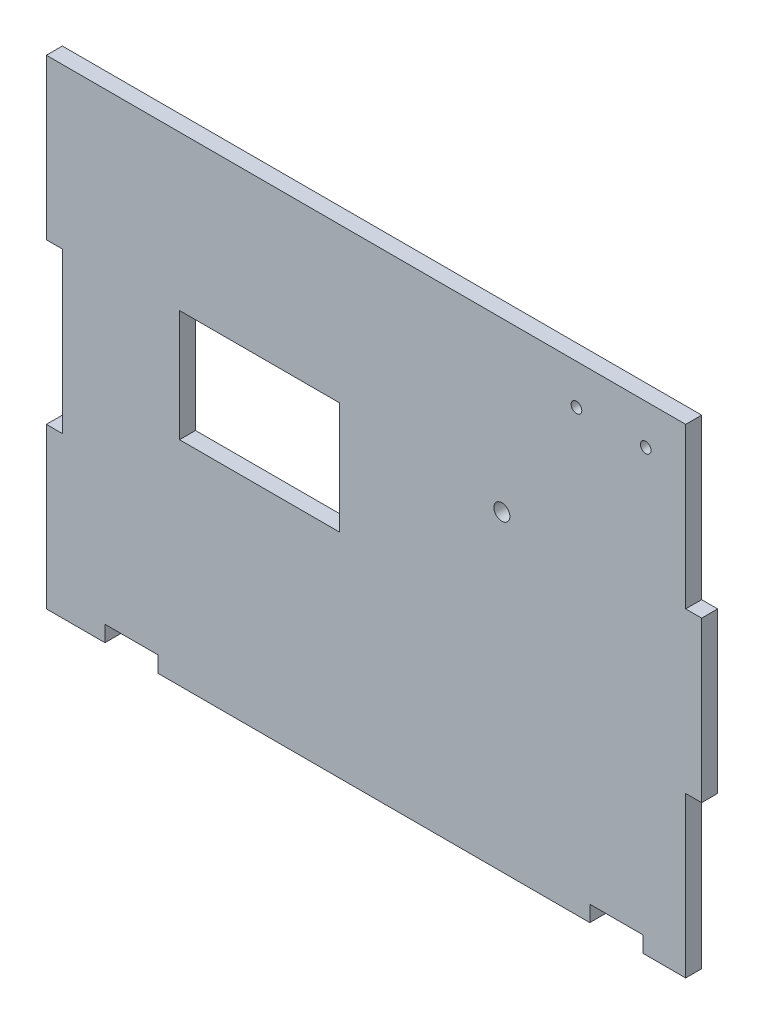
from build123d import *

# Parameters (mm, degrees)
MODEL_R             = 1
MODEL_R_2           = 1.5
MODEL_W             = 30
MODEL_H             = 21
BOSS_EXTRUDE1_DEPTH = 3


with BuildPart() as part:
    # Model → Boss-Extrude1 (new body)
    with BuildSketch(Plane.XY):
        Polygon((71.207281269, 100.913104874), (71.207281269, 70.913104874), (68.207281269, 70.913104874), (68.207281269, 40.913104874), (60.207281269, 40.913104874), (60.207281269, 43.913104874), (50.207281269, 43.913104874), (50.207281269, 40.913104874), (-30.792718731, 40.913104874), (-30.792718731, 43.913104874), (-40.792718731, 43.913104874), (-40.792718731, 40.913104874), (-51.792718731, 40.913104874), (-51.792718731, 70.913104874), (-48.792718731, 70.913104874), (-48.792718731, 100.913104874), (-51.792718731, 100.913104874), (-51.792718731, 130.913104874), (68.207281269, 130.913104874), (68.207281269, 100.913104874), align=None)
        with Locations((47.707281269, 123.413104874)):
            Circle(MODEL_R, mode=Mode.SUBTRACT)
        with Locations((60.707281269, 123.413104874)):
            Circle(MODEL_R, mode=Mode.SUBTRACT)
        with Locations((33.707281269, 99.413104874)):
            Circle(MODEL_R_2, mode=Mode.SUBTRACT)
        with Locations((-11.792718731, 91.413104874)):
            Rectangle(MODEL_W, MODEL_H, mode=Mode.SUBTRACT)
    extrude(amount=BOSS_EXTRUDE1_DEPTH)


solid = part.part
